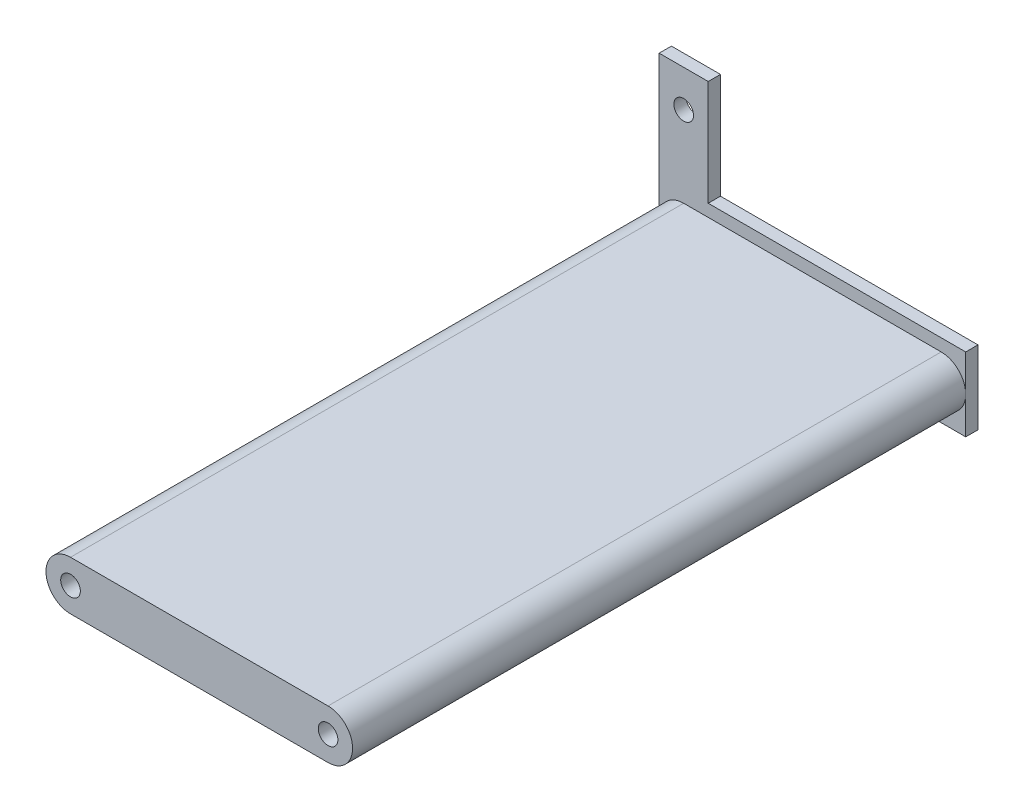
from build123d import *

# Parameters (mm, degrees)
SKETCH1_R           = 1.016
BOSS_EXTRUDE1_DEPTH = 1.27
SKETCH2_R           = 1.016
BOSS_EXTRUDE3_DEPTH = 63.5


with BuildPart() as part:
    # Sketch1 → Boss-Extrude1 (new body)
    with BuildSketch(Plane.XY):
        Polygon((-36.869116619, 17.792333901), (-36.869116619, -0.749666099), (-5.119116619, -0.749666099), (-5.119116619, 6.870333901), (-31.789116619, 6.870333901), (-31.789116619, 17.792333901), align=None)
        with Locations((-34.329116619, 13.982333901)):
            Circle(SKETCH1_R, mode=Mode.SUBTRACT)
        with Locations((-34.329116619, 3.060333901)):
            Circle(SKETCH1_R, mode=Mode.SUBTRACT)
        with Locations((-7.659116619, 3.060333901)):
            Circle(SKETCH1_R, mode=Mode.SUBTRACT)
    extrude(amount=BOSS_EXTRUDE1_DEPTH)

    # Sketch2 → Boss-Extrude3 (add)
    with BuildSketch(Plane.XY.offset(1.27)):
        with BuildLine():
            Line((-34.329116619, 5.600333901), (-7.659116619, 5.600333901))
            ThreePointArc((-7.659116619, 5.600333901), (-5.119116619, 3.060333901), (-7.659116619, 0.520333901))
            Line((-7.659116619, 0.520333901), (-34.329116619, 0.520333901))
            ThreePointArc((-34.329116619, 0.520333901), (-36.869116619, 3.060333901), (-34.329116619, 5.600333901))
        make_face()
        with Locations((-34.329116619, 3.060333901)):
            Circle(SKETCH2_R, mode=Mode.SUBTRACT)
        with Locations((-7.659116619, 3.060333901)):
            Circle(SKETCH2_R, mode=Mode.SUBTRACT)
    extrude(amount=BOSS_EXTRUDE3_DEPTH)


solid = part.part
